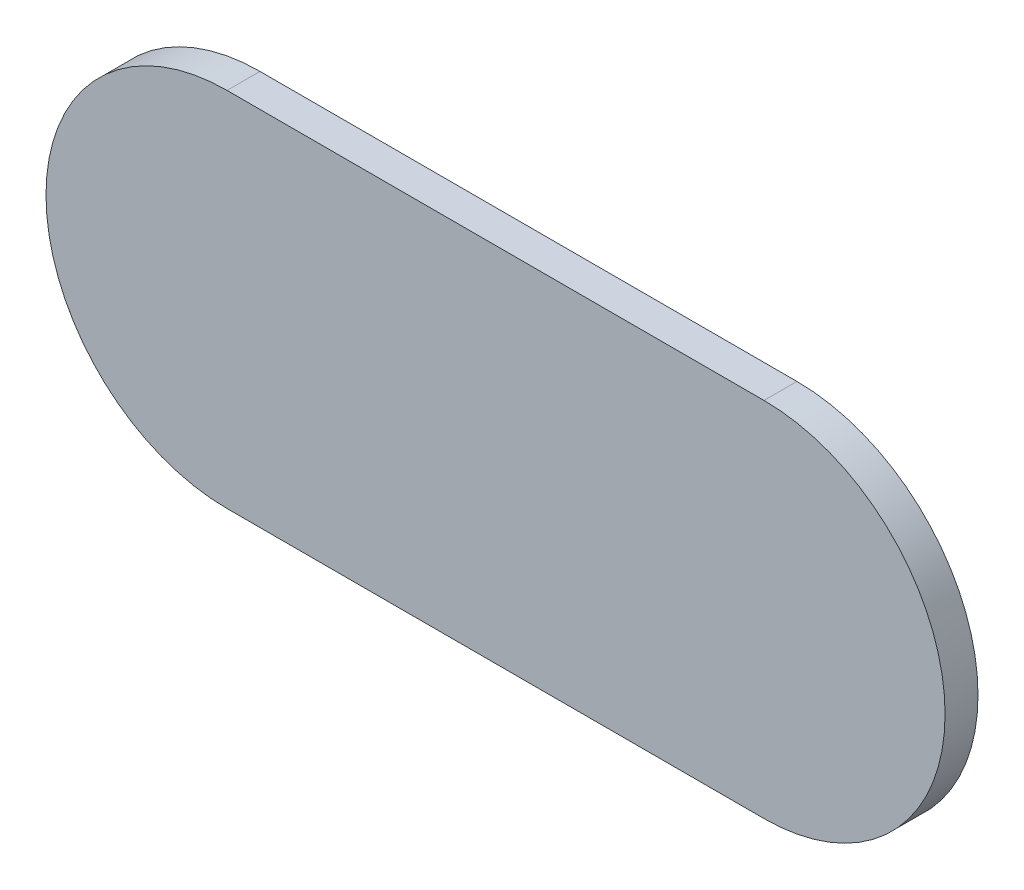
from build123d import *

# Parameters (mm, degrees)
BOSS_EXTRUDE1_DEPTH = 0.5


with BuildPart() as part:
    # Sketch1 → Boss-Extrude1 (new body)
    with BuildSketch(Plane.XY):
        with BuildLine():
            Line((-46.586072137, -2.277616218), (-38.430768685, -2.277616218))
            ThreePointArc((-38.430768685, -2.277616218), (-35.680768685, -5.027616218), (-38.430768685, -7.777616218))
            Line((-38.430768685, -7.777616218), (-46.586072137, -7.777616218))
            ThreePointArc((-46.586072137, -7.777616218), (-49.336072137, -5.027616218), (-46.586072137, -2.277616218))
        make_face()
    extrude(amount=BOSS_EXTRUDE1_DEPTH)


solid = part.part
